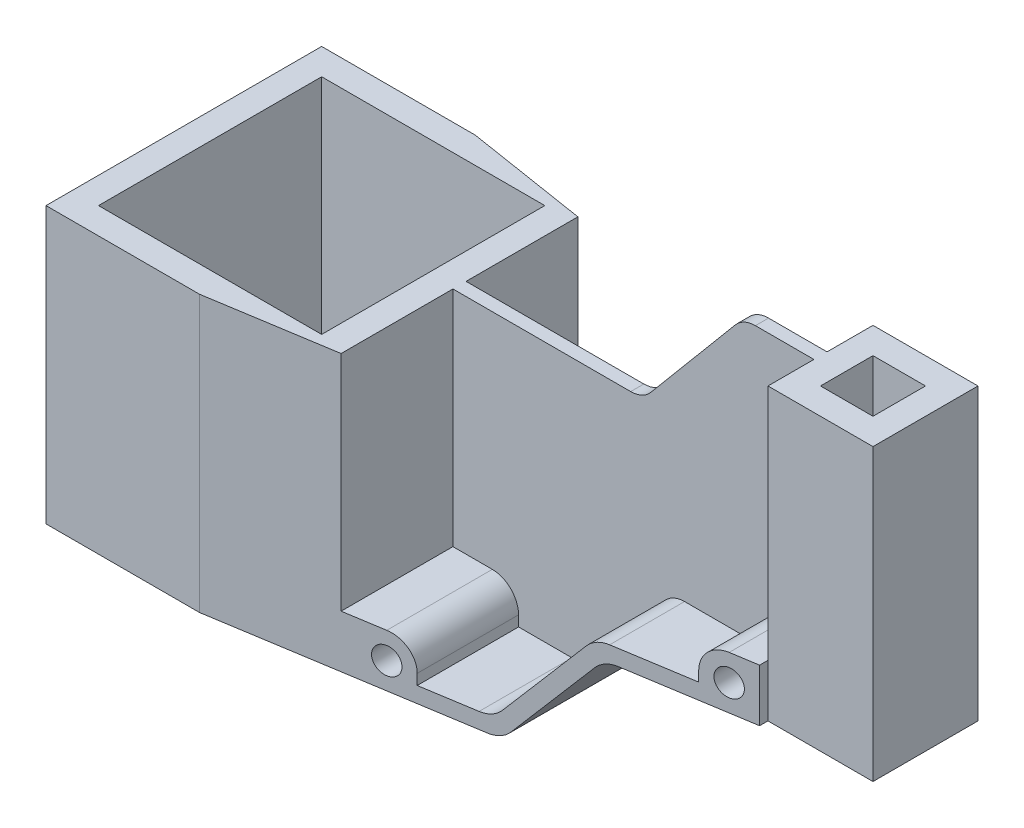
from build123d import *

# Parameters (mm, degrees)
SKETCH1_W           = 282.5
SKETCH1_H           = 105
BOSS_EXTRUDE1_DEPTH = 150.5
SKETCH2_W           = 155
SKETCH2_H           = 105
CUT_EXTRUDE1_DEPTH  = 45.5
SKETCH3_W           = 50
SKETCH3_H           = 50
CUT_EXTRUDE2_DEPTH  = 85
SKETCH4_R           = 5
CUT_EXTRUDE3_DEPTH  = 50
SKETCH5_R           = 5
CUT_EXTRUDE4_DEPTH  = 50
CUT_EXTRUDE5_DEPTH  = 106
CUT_EXTRUDE6_DEPTH  = 106
SKETCH8_R           = 5
CUT_EXTRUDE7_DEPTH  = 50
CUT_EXTRUDE8_DEPTH  = 50
SKETCH10_R          = 5
CUT_EXTRUDE9_DEPTH  = 106
SKETCH11_R          = 5
CUT_EXTRUDE10_DEPTH = 106
SKETCH12_W          = 85
SKETCH12_H          = 85
CUT_EXTRUDE11_DEPTH = 106
SKETCH13_W          = 40
SKETCH13_H          = 32.5
CUT_EXTRUDE12_DEPTH = 151.5
SKETCH14_W          = 20
SKETCH14_H          = 20
CUT_EXTRUDE13_DEPTH = 151.5
CUT_EXTRUDE14_DEPTH = 106
FILLET1_R           = 10
FILLET2_R           = 10
FILLET3_R           = 10


with BuildPart() as part:
    # Sketch1 → Boss-Extrude1 (new body)
    with BuildSketch(Plane(origin=(0, 0, 0), x_dir=(1, 0, 0), z_dir=(0, 1, 0))):
        with Locations((-141.25, -52.5)):
            Rectangle(SKETCH1_W, SKETCH1_H)
    extrude(amount=BOSS_EXTRUDE1_DEPTH)

    # Sketch2 → Cut-Extrude1 (cut)
    with BuildSketch(Plane(origin=(0, 150.5, 0), x_dir=(1, 0, 0), z_dir=(0, 1, 0))):
        with Locations((-205, -52.5)):
            Rectangle(SKETCH2_W, SKETCH2_H)
    extrude(amount=-CUT_EXTRUDE1_DEPTH, mode=Mode.SUBTRACT)

    # Sketch3 → Cut-Extrude2 (cut)
    with BuildSketch(Plane(origin=(0, 105, 0), x_dir=(1, 0, 0), z_dir=(0, 1, 0))):
        with Locations((-152.5, -80)):
            Rectangle(SKETCH3_W, SKETCH3_H)
        with Locations((-152.5, -25)):
            Rectangle(SKETCH3_W, SKETCH3_H)
    extrude(amount=-CUT_EXTRUDE2_DEPTH, mode=Mode.SUBTRACT)

    # Sketch4 → Cut-Extrude3 (cut)
    with BuildSketch(Plane.XY.offset(105)):
        with Locations((-162.5, 10)):
            Circle(SKETCH4_R)
        with BuildLine():
            Line((-152.5, 6), (-127.5, 6))
            Line((-127.5, 6), (-127.5, 105))
            Line((-127.5, 105), (-177.5, 105))
            Line((-177.5, 105), (-177.5, 20))
            Line((-177.5, 20), (-162.5, 20))
            ThreePointArc((-162.5, 20), (-155.428932188, 17.071067812), (-152.5, 10))
            Line((-152.5, 10), (-152.5, 6))
        make_face()
    extrude(amount=-CUT_EXTRUDE3_DEPTH, mode=Mode.SUBTRACT)

    # Sketch5 → Cut-Extrude4 (cut)
    with BuildSketch(Plane(origin=(0, 0, 0), x_dir=(-1, 0, 0), z_dir=(0, 0, -1))):
        with Locations((162.5, 10)):
            Circle(SKETCH5_R)
        with BuildLine():
            Line((127.5, 105), (177.5, 105))
            Line((177.5, 105), (177.5, 20))
            Line((177.5, 20), (162.5, 20))
            ThreePointArc((162.5, 20), (155.428932188, 17.071067812), (152.5, 10))
            Line((152.5, 10), (152.5, 6))
            Line((152.5, 6), (127.5, 6))
            Line((127.5, 6), (127.5, 105))
        make_face()
    extrude(amount=-CUT_EXTRUDE4_DEPTH, mode=Mode.SUBTRACT)

    # Sketch6 → Cut-Extrude5 (cut, through all)
    with BuildSketch(Plane.XY.offset(105)):
        Polygon((0, 40), (-91.138168804, 40), (-124.702154051, 0), (0, 0), align=None)
    extrude(amount=-CUT_EXTRUDE5_DEPTH, mode=Mode.SUBTRACT)

    # Sketch7 → Cut-Extrude6 (cut, through all)
    with BuildSketch(Plane.XY.offset(105)):
        Polygon((-127.5, 105), (-105.130575467, 105), (-66.951542249, 150.5), (-127.5, 150.5), align=None)
    extrude(amount=-CUT_EXTRUDE6_DEPTH, mode=Mode.SUBTRACT)

    # Sketch8 → Cut-Extrude7 (cut)
    with BuildSketch(Plane.XY.offset(105)):
        with Locations((-50, 50)):
            Circle(SKETCH8_R)
        with BuildLine():
            Line((-40, 150.5), (-66.951542249, 150.5))
            Line((-66.951542249, 150.5), (-105.130575467, 105))
            Line((-105.130575467, 105), (-127.5, 105))
            Line((-127.5, 105), (-127.5, 6))
            Line((-127.5, 6), (-93.936014753, 46))
            Line((-93.936014753, 46), (-60, 46))
            Line((-60, 46), (-60, 50))
            ThreePointArc((-60, 50), (-57.071067812, 57.071067812), (-50, 60))
            Line((-50, 60), (-40, 60))
            Line((-40, 60), (-40, 150.5))
        make_face()
    extrude(amount=-CUT_EXTRUDE7_DEPTH, mode=Mode.SUBTRACT)

    # Sketch9 → Cut-Extrude8 (cut)
    with BuildSketch(Plane(origin=(0, 0, 0), x_dir=(-1, 0, 0), z_dir=(0, 0, -1))):
        with BuildLine():
            Line((66.951542249, 150.5), (40, 150.5))
            Line((40, 150.5), (40, 60))
            Line((40, 60), (50, 60))
            ThreePointArc((50, 60), (57.071067812, 57.071067812), (60, 50))
            Line((60, 50), (60, 46))
            Line((60, 46), (93.936014753, 46))
            Line((93.936014753, 46), (127.5, 6))
            Line((127.5, 6), (127.5, 105))
            Line((127.5, 105), (105.130575467, 105))
            Line((105.130575467, 105), (66.951542249, 150.5))
        make_face()
    extrude(amount=-CUT_EXTRUDE8_DEPTH, mode=Mode.SUBTRACT)

    # Sketch10 → Cut-Extrude9 (cut, through all)
    with BuildSketch(Plane(origin=(0, 0, 0), x_dir=(-1, 0, 0), z_dir=(0, 0, -1))):
        with Locations((50, 50)):
            Circle(SKETCH10_R)
    extrude(amount=-CUT_EXTRUDE9_DEPTH, mode=Mode.SUBTRACT)

    # Sketch11 → Cut-Extrude10 (cut, through all)
    with BuildSketch(Plane(origin=(0, 0, 0), x_dir=(-1, 0, 0), z_dir=(0, 0, -1))):
        with Locations((162.5, 10)):
            Circle(SKETCH11_R)
    extrude(amount=-CUT_EXTRUDE10_DEPTH, mode=Mode.SUBTRACT)

    # Sketch12 → Cut-Extrude11 (cut, through all)
    with BuildSketch(Plane(origin=(0, 105, 0), x_dir=(1, 0, 0), z_dir=(0, 1, 0))):
        with Locations((-230, -52.5)):
            Rectangle(SKETCH12_W, SKETCH12_H)
    extrude(amount=-CUT_EXTRUDE11_DEPTH, mode=Mode.SUBTRACT)

    # Sketch13 → Cut-Extrude12 (cut, through all)
    with BuildSketch(Plane(origin=(0, 150.5, 0), x_dir=(1, 0, 0), z_dir=(0, 1, 0))):
        with Locations((-20, -88.75)):
            Rectangle(SKETCH13_W, SKETCH13_H)
        with Locations((-20, -16.25)):
            Rectangle(SKETCH13_W, SKETCH13_H)
    extrude(amount=-CUT_EXTRUDE12_DEPTH, mode=Mode.SUBTRACT)

    # Sketch14 → Cut-Extrude13 (cut, through all)
    with BuildSketch(Plane(origin=(0, 150.5, 0), x_dir=(1, 0, 0), z_dir=(0, 1, 0))):
        with Locations((-20, -52.5)):
            Rectangle(SKETCH14_W, SKETCH14_H)
    extrude(amount=-CUT_EXTRUDE13_DEPTH, mode=Mode.SUBTRACT)

    # Sketch15 → Cut-Extrude14 (cut, through all)
    with BuildSketch(Plane(origin=(0, 105, 0), x_dir=(1, 0, 0), z_dir=(0, 1, 0))):
        Polygon((-224, 0), (-20, -32.5), (-20, 0), align=None)
        Polygon((-224, -105), (-20, -72.5), (-20, -105), align=None)
    extrude(amount=-CUT_EXTRUDE14_DEPTH, mode=Mode.SUBTRACT)

    # Fillet1
    fillet1_edges = [part.edges().sort_by_distance(p)[0] for p in [
        (-93.936014753, 46, 69.639510979),
        (-93.936014753, 46, 35.360489021),
        (-127.5, 6, 72.313112745),
        (-127.5, 6, 32.686887255),
    ]]
    fillet(fillet1_edges, radius=FILLET1_R)

    # Fillet2
    fillet2_edges = [part.edges().sort_by_distance(p)[0] for p in [
        (-124.702154051, 0, 52.5),
        (-91.138168804, 40, 52.5),
    ]]
    fillet(fillet2_edges, radius=FILLET2_R)

    # Fillet3
    fillet3_edges = [part.edges().sort_by_distance(p)[0] for p in [
        (-105.130575467, 105, 52.5),
        (-66.951542249, 150.5, 52.5),
    ]]
    fillet(fillet3_edges, radius=FILLET3_R)


solid = part.part
